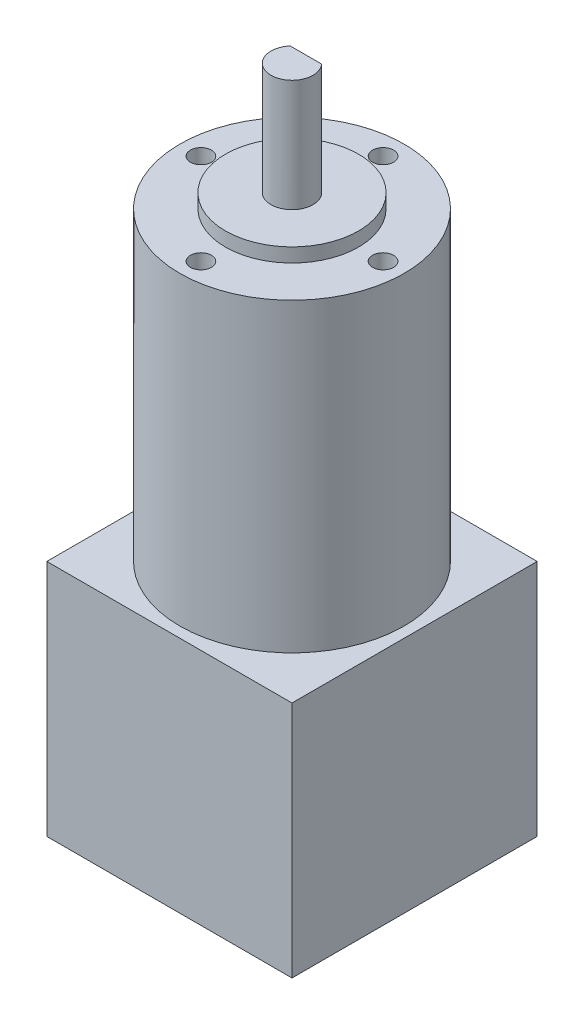
from build123d import *

# Parameters (mm, degrees)
SKETCH1_W           = 35
SKETCH1_H           = 35
BOSS_EXTRUDE1_DEPTH = 34
SKETCH2_R           = 16
BOSS_EXTRUDE2_DEPTH = 43.6
SKETCH3_R           = 9.5
BOSS_EXTRUDE3_DEPTH = 2
SKETCH4_R           = 3
BOSS_EXTRUDE4_DEPTH = 16
CUT_EXTRUDE1_DEPTH  = 12
SKETCH6_R           = 1.5
CUT_EXTRUDE2_DEPTH  = 7


with BuildPart() as part:
    # Sketch1 → Boss-Extrude1 (new body)
    with BuildSketch(Plane(origin=(0, 0, 0), x_dir=(1, 0, 0), z_dir=(0, 1, 0))):
        Rectangle(SKETCH1_W, SKETCH1_H)
    extrude(amount=BOSS_EXTRUDE1_DEPTH)

    # Sketch2 → Boss-Extrude2 (add)
    with BuildSketch(Plane(origin=(0, 34, 0), x_dir=(1, 0, 0), z_dir=(0, 1, 0))):
        Circle(SKETCH2_R)
    extrude(amount=BOSS_EXTRUDE2_DEPTH)

    # Sketch3 → Boss-Extrude3 (add)
    with BuildSketch(Plane(origin=(0, 77.6, 0), x_dir=(1, 0, 0), z_dir=(0, 1, 0))):
        Circle(SKETCH3_R)
    extrude(amount=BOSS_EXTRUDE3_DEPTH)

    # Sketch4 → Boss-Extrude4 (add)
    with BuildSketch(Plane(origin=(0, 79.6, 0), x_dir=(1, 0, 0), z_dir=(0, 1, 0))):
        Circle(SKETCH4_R)
    extrude(amount=BOSS_EXTRUDE4_DEPTH)

    # Sketch5 → Cut-Extrude1 (cut)
    with BuildSketch(Plane(origin=(0, 95.6, 0), x_dir=(1, 0, 0), z_dir=(0, 1, 0))):
        with BuildLine():
            Line((2.236067977, 2), (-2.236067977, 2))
            ThreePointArc((-2.236067977, 2), (0, 3), (2.236067977, 2))
        make_face()
    extrude(amount=-CUT_EXTRUDE1_DEPTH, mode=Mode.SUBTRACT)

    # Sketch6 → Cut-Extrude2 (cut)
    with BuildSketch(Plane(origin=(0, 77.6, 0), x_dir=(1, 0, 0), z_dir=(0, 1, 0))):
        with Locations((0, 13)):
            Circle(SKETCH6_R)
        with Locations((13, 0)):
            Circle(SKETCH6_R)
        with Locations((-13, 0)):
            Circle(SKETCH6_R)
        with Locations((0, -13)):
            Circle(SKETCH6_R)
    extrude(amount=-CUT_EXTRUDE2_DEPTH, mode=Mode.SUBTRACT)


solid = part.part
